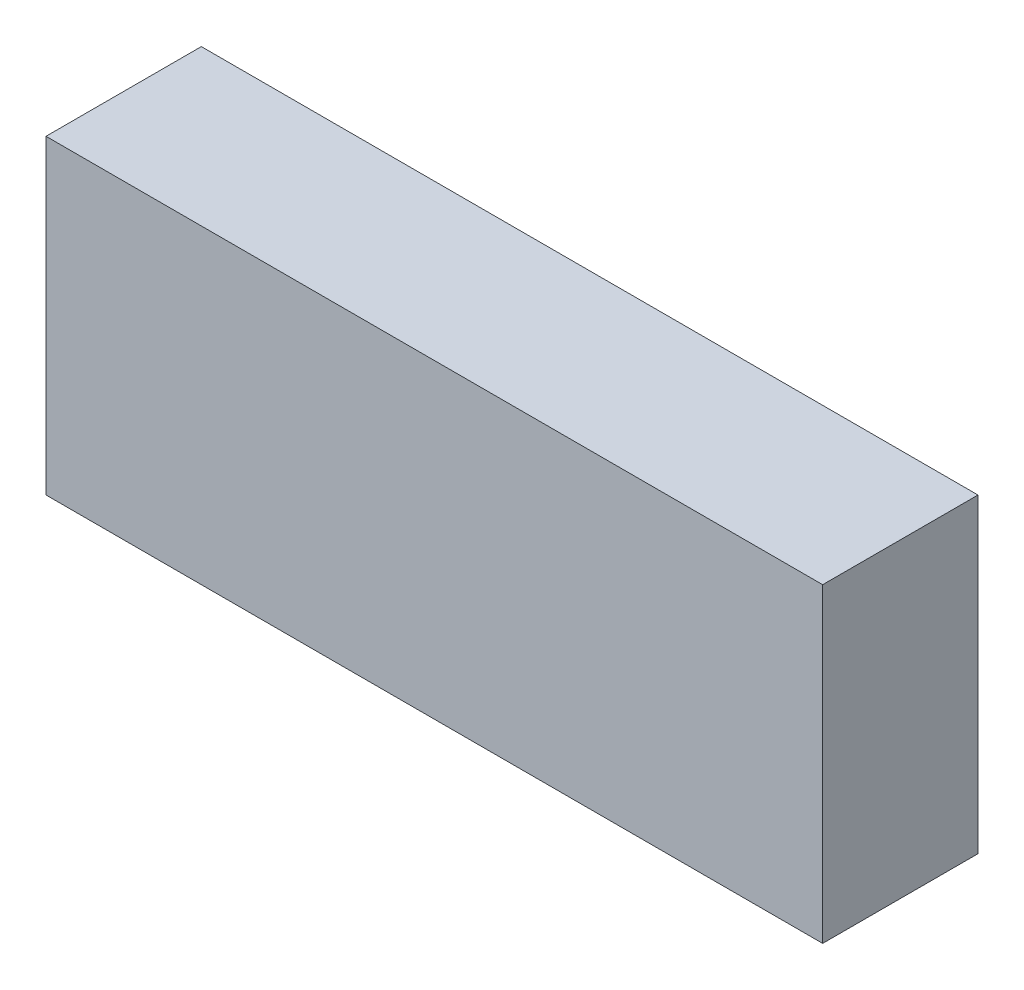
from build123d import *

# Parameters (mm, degrees)
ESBO_O1_W                = 50
ESBO_O1_H                = 20
RESSALTO_EXTRUS_O1_DEPTH = 10


with BuildPart() as part:
    # Esboço1 → Ressalto-extrusão1 (new body)
    with BuildSketch(Plane.XY):
        Rectangle(ESBO_O1_W, ESBO_O1_H)
    extrude(amount=RESSALTO_EXTRUS_O1_DEPTH)


solid = part.part
